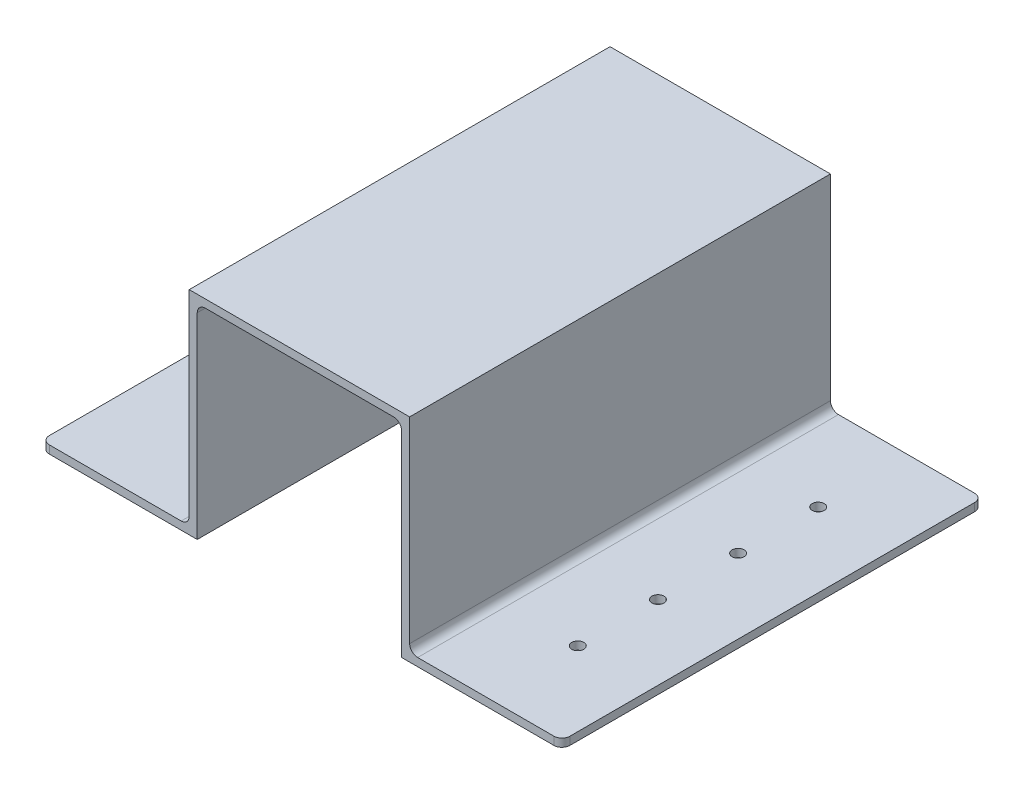
from build123d import *

# Parameters (mm, degrees)
BOSS_EXTRUDE1_DEPTH = 105
FILLET2_R           = 2
FILLET3_R           = 2
FILLET4_R           = 2
FILLET5_R           = 2
SKETCH2_R           = 1.5
CUT_EXTRUDE1_DEPTH  = 105
FILLET6_R           = 2


with BuildPart() as part:
    # Sketch1 → Boss-Extrude1 (new body)
    with BuildSketch(Plane.XY):
        Polygon((-42.084779145, 1.426065285), (8.915220855, 1.426065285), (8.915220855, -49.573934715), (48.915220855, -49.573934715), (48.915220855, -47.573934715), (10.915220855, -47.573934715), (10.915220855, 3.426065285), (-44.084779145, 3.426065285), (-44.084779145, -47.573934715), (-80.999498671, -47.573934715), (-80.999498671, -49.573934715), (-42.084779145, -49.573934715), align=None)
    extrude(amount=BOSS_EXTRUDE1_DEPTH)

    # Fillet2
    fillet2_edges = [part.edges().sort_by_distance(p)[0] for p in [
        (-44.084779145, -47.573934715, 52.5),
    ]]
    fillet(fillet2_edges, radius=FILLET2_R)

    # Fillet3
    fillet3_edges = [part.edges().sort_by_distance(p)[0] for p in [
        (-42.084779145, 1.426065285, 52.5),
    ]]
    fillet(fillet3_edges, radius=FILLET3_R)

    # Fillet4
    fillet4_edges = [part.edges().sort_by_distance(p)[0] for p in [
        (8.915220855, 1.426065285, 52.5),
    ]]
    fillet(fillet4_edges, radius=FILLET4_R)

    # Fillet5
    fillet5_edges = [part.edges().sort_by_distance(p)[0] for p in [
        (10.915220855, -47.573934715, 52.5),
    ]]
    fillet(fillet5_edges, radius=FILLET5_R)

    # Sketch2 → Cut-Extrude1 (cut)
    with BuildSketch(Plane(origin=(0, -47.573934715, 0), x_dir=(1, 0, 0), z_dir=(0, 1, 0))):
        with Locations((-63.542138908, -42.5)):
            Circle(SKETCH2_R)
        with Locations((-63.542138908, -22.5)):
            Circle(SKETCH2_R)
        with Locations((-63.542138908, -82.5)):
            Circle(SKETCH2_R)
        with Locations((-63.542138908, -62.5)):
            Circle(SKETCH2_R)
        with Locations((30.372580618, -82.5)):
            Circle(SKETCH2_R)
        with Locations((30.372580618, -62.5)):
            Circle(SKETCH2_R)
        with Locations((30.372580618, -42.5)):
            Circle(SKETCH2_R)
        with Locations((30.372580618, -22.5)):
            Circle(SKETCH2_R)
    extrude(amount=-CUT_EXTRUDE1_DEPTH, mode=Mode.SUBTRACT)

    # Fillet6
    fillet6_edges = [part.edges().sort_by_distance(p)[0] for p in [
        (-80.999498671, -48.573934715, 0),
        (48.915220855, -48.573934715, 0),
        (48.915220855, -48.573934715, 105),
        (-80.999498671, -48.573934715, 105),
    ]]
    fillet(fillet6_edges, radius=FILLET6_R)


solid = part.part
